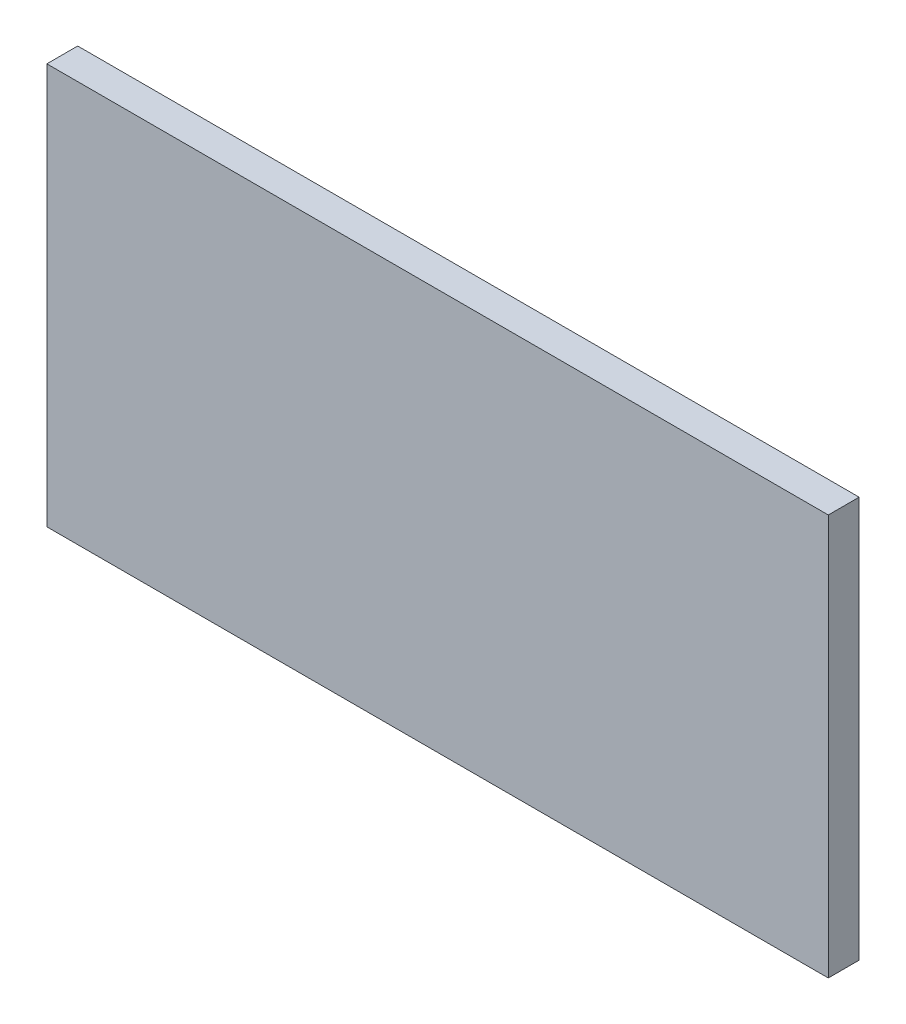
from build123d import *

# Parameters (mm, degrees)
SKETCH1_W           = 76
SKETCH1_H           = 39
BOSS_EXTRUDE1_DEPTH = 3


with BuildPart() as part:
    # Sketch1 → Boss-Extrude1 (new body)
    with BuildSketch(Plane.XY):
        with Locations((38, 19.5)):
            Rectangle(SKETCH1_W, SKETCH1_H)
    extrude(amount=BOSS_EXTRUDE1_DEPTH)


solid = part.part
